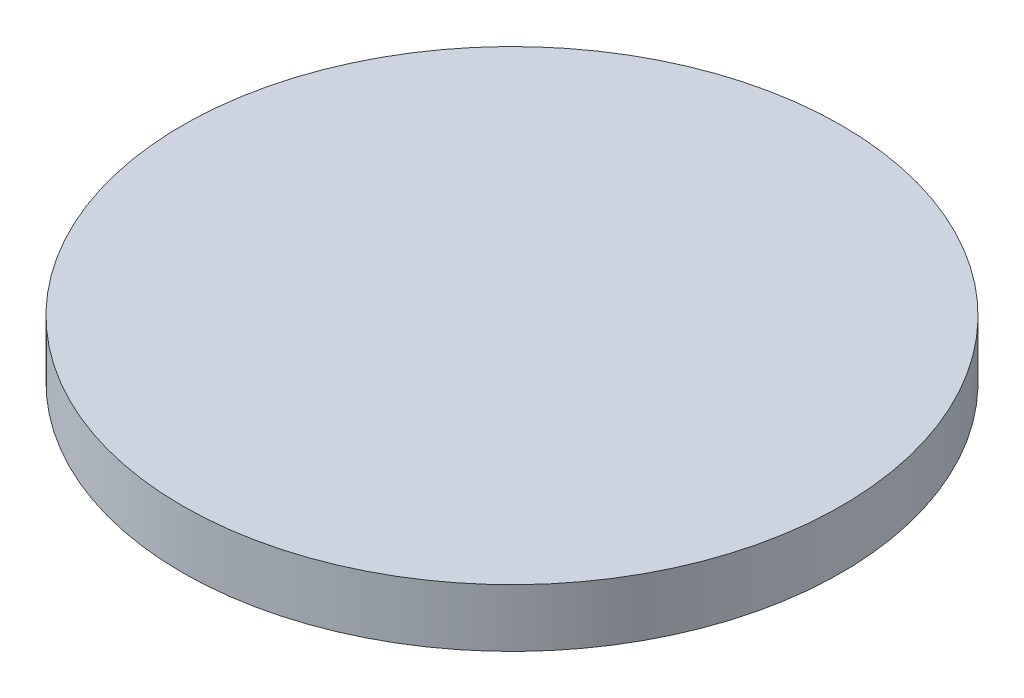
from build123d import *

# Parameters (mm, degrees)
SKETCH1_R           = 36.195
BOSS_EXTRUDE1_DEPTH = 6.35


with BuildPart() as part:
    # Sketch1 → Boss-Extrude1 (new body)
    with BuildSketch(Plane(origin=(0, 0, 0), x_dir=(1, 0, 0), z_dir=(0, 1, 0))):
        Circle(SKETCH1_R)
    extrude(amount=BOSS_EXTRUDE1_DEPTH)


solid = part.part
